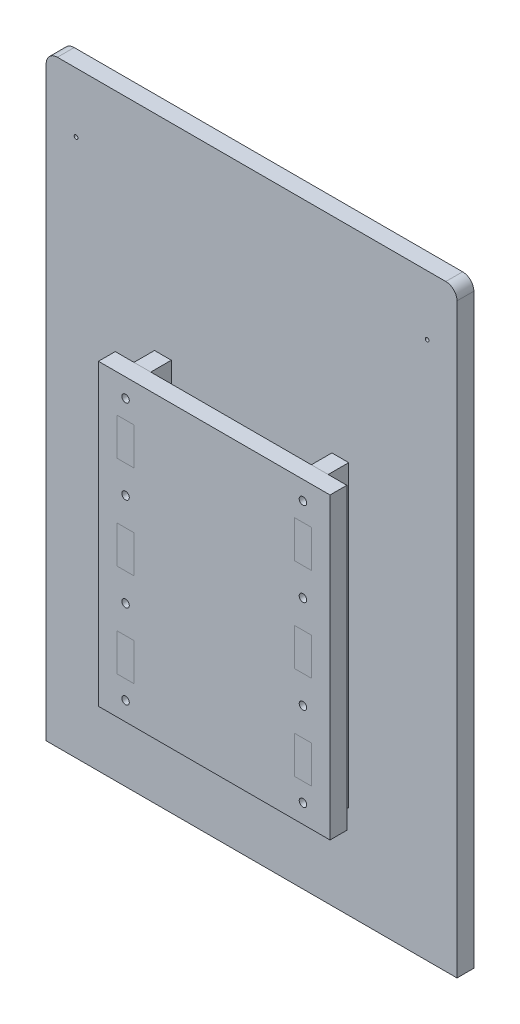
from build123d import *

# Parameters (mm, degrees)
MODEL_R            = 1
MODEL_W            = 124
MODEL_H            = 160
MODEL_R_2          = 2
MODEL_W_2          = 9
MODEL_H_2          = 20
MODEL_H_3          = 30
BOSS_EXTRU_1_DEPTH = 9
BOSS_EXTRU_3_START = 9
MODEL_3_W          = 9
MODEL_3_H          = 20
MODEL_3_R          = 2
MODEL_3_H_2        = 30
BOSS_EXTRU_3_DEPTH = 11
MODEL_4_W          = 9
MODEL_4_H          = 20
BOSS_EXTRU_4_DEPTH = 9
MODEL_5_W          = 9
MODEL_5_H          = 20
BOSS_EXTRU_5_DEPTH = 9
BOSS_EXTRU_6_START = 20
MODEL_7_W          = 9
MODEL_7_H          = 20
MODEL_7_R          = 2
MODEL_7_H_2        = 30
BOSS_EXTRU_6_DEPTH = 9
BOSS_EXTRU_7_START = 20
MODEL_8_W          = 9
MODEL_8_H          = 20
BOSS_EXTRU_7_DEPTH = 9
BOSS_EXTRU_8_START = 20
MODEL_9_W          = 9
MODEL_9_H          = 20
BOSS_EXTRU_8_DEPTH = 9


with BuildPart() as part:
    # Model → Boss.-Extru.1 (new body)
    with BuildSketch(Plane.XY):
        with BuildLine():
            Line((110, 0), (110, 314))
            ThreePointArc((110, 314), (108.242640687, 318.242640687), (104, 320))
            Line((104, 320), (0, 320))
            Line((0, 320), (-104, 320))
            ThreePointArc((-104, 320), (-108.242640687, 318.242640687), (-110, 314))
            Line((-110, 314), (-110, 0))
            Line((-110, 0), (0, 0))
            Line((0, 0), (110, 0))
        make_face()
        with Locations((94, 288)):
            Circle(MODEL_R, mode=Mode.SUBTRACT)
        with Locations((-94, 288)):
            Circle(MODEL_R, mode=Mode.SUBTRACT)
        with Locations((0, 130)):
            Rectangle(MODEL_W, MODEL_H, mode=Mode.SUBTRACT)
        with Locations((0, 130)):
            Rectangle(MODEL_W, MODEL_H)
        with Locations((47.5, 155)):
            Circle(MODEL_R_2, mode=Mode.SUBTRACT)
        with Locations((47.5, 60)):
            Circle(MODEL_R_2, mode=Mode.SUBTRACT)
        with Locations((-47.5, 60)):
            Circle(MODEL_R_2, mode=Mode.SUBTRACT)
        with Locations((-47.5, 105)):
            Circle(MODEL_R_2, mode=Mode.SUBTRACT)
        with Locations((-47.5, 155)):
            Circle(MODEL_R_2, mode=Mode.SUBTRACT)
        with Locations((-47.5, 200)):
            Circle(MODEL_R_2, mode=Mode.SUBTRACT)
        with Locations((47.5, 105)):
            Circle(MODEL_R_2, mode=Mode.SUBTRACT)
        with Locations((47.5, 200)):
            Circle(MODEL_R_2, mode=Mode.SUBTRACT)
        with Locations((-47.5, 130)):
            Rectangle(MODEL_W_2, MODEL_H_2, mode=Mode.SUBTRACT)
        with Locations((-47.5, 80)):
            Rectangle(MODEL_W_2, MODEL_H_2, mode=Mode.SUBTRACT)
        with Locations((-47.5, 180)):
            Rectangle(MODEL_W_2, MODEL_H_2, mode=Mode.SUBTRACT)
        with Locations((47.5, 130)):
            Rectangle(MODEL_W_2, MODEL_H_2, mode=Mode.SUBTRACT)
        with Locations((47.5, 80)):
            Rectangle(MODEL_W_2, MODEL_H_2, mode=Mode.SUBTRACT)
        with Locations((47.5, 180)):
            Rectangle(MODEL_W_2, MODEL_H_2, mode=Mode.SUBTRACT)
        Polygon((-52, 170), (-52, 190), (-52, 210), (-62, 210), (-62, 50), (-52, 50), (-52, 70), (-52, 90), (-52, 120), (-52, 140), align=None)
        with Locations((-47.5, 200)):
            Rectangle(MODEL_W_2, MODEL_H_2)
        with Locations((-47.5, 200)):
            Circle(MODEL_R_2, mode=Mode.SUBTRACT)
        with Locations((-47.5, 155)):
            Rectangle(MODEL_W_2, MODEL_H_3)
        with Locations((-47.5, 155)):
            Circle(MODEL_R_2, mode=Mode.SUBTRACT)
        with Locations((-47.5, 105)):
            Rectangle(MODEL_W_2, MODEL_H_3)
        with Locations((-47.5, 105)):
            Circle(MODEL_R_2, mode=Mode.SUBTRACT)
        with Locations((-47.5, 60)):
            Rectangle(MODEL_W_2, MODEL_H_2)
        with Locations((-47.5, 60)):
            Circle(MODEL_R_2, mode=Mode.SUBTRACT)
        Polygon((62, 210), (52, 210), (52, 190), (52, 170), (52, 140), (52, 120), (52, 90), (52, 70), (52, 50), (62, 50), align=None)
        with Locations((47.5, 60)):
            Rectangle(MODEL_W_2, MODEL_H_2)
        with Locations((47.5, 60)):
            Circle(MODEL_R_2, mode=Mode.SUBTRACT)
        with Locations((47.5, 105)):
            Rectangle(MODEL_W_2, MODEL_H_3)
        with Locations((47.5, 105)):
            Circle(MODEL_R_2, mode=Mode.SUBTRACT)
        with Locations((47.5, 155)):
            Rectangle(MODEL_W_2, MODEL_H_3)
        with Locations((47.5, 155)):
            Circle(MODEL_R_2, mode=Mode.SUBTRACT)
        with Locations((47.5, 200)):
            Rectangle(MODEL_W_2, MODEL_H_2)
        with Locations((47.5, 200)):
            Circle(MODEL_R_2, mode=Mode.SUBTRACT)
    extrude(amount=BOSS_EXTRU_1_DEPTH)


with BuildPart() as body_2:
    # Model_3 → Boss.-Extru.3 (new body)
    with BuildSketch(Plane.XY.offset(BOSS_EXTRU_3_START)):
        with Locations((-47.5, 200)):
            Rectangle(MODEL_3_W, MODEL_3_H)
        with Locations((-47.5, 200)):
            Circle(MODEL_3_R, mode=Mode.SUBTRACT)
        with Locations((-47.5, 155)):
            Rectangle(MODEL_3_W, MODEL_3_H_2)
        with Locations((-47.5, 155)):
            Circle(MODEL_3_R, mode=Mode.SUBTRACT)
        with Locations((-47.5, 105)):
            Rectangle(MODEL_3_W, MODEL_3_H_2)
        with Locations((-47.5, 105)):
            Circle(MODEL_3_R, mode=Mode.SUBTRACT)
        with Locations((-47.5, 60)):
            Rectangle(MODEL_3_W, MODEL_3_H)
        with Locations((-47.5, 60)):
            Circle(MODEL_3_R, mode=Mode.SUBTRACT)
        with Locations((-47.5, 80)):
            Rectangle(MODEL_3_W, MODEL_3_H)
        with Locations((-47.5, 130)):
            Rectangle(MODEL_3_W, MODEL_3_H)
        with Locations((-47.5, 180)):
            Rectangle(MODEL_3_W, MODEL_3_H)
        with Locations((47.5, 200)):
            Rectangle(MODEL_3_W, MODEL_3_H)
        with Locations((47.5, 200)):
            Circle(MODEL_3_R, mode=Mode.SUBTRACT)
        with Locations((47.5, 180)):
            Rectangle(MODEL_3_W, MODEL_3_H)
        with Locations((47.5, 155)):
            Rectangle(MODEL_3_W, MODEL_3_H_2)
        with Locations((47.5, 155)):
            Circle(MODEL_3_R, mode=Mode.SUBTRACT)
        with Locations((47.5, 130)):
            Rectangle(MODEL_3_W, MODEL_3_H)
        with Locations((47.5, 105)):
            Rectangle(MODEL_3_W, MODEL_3_H_2)
        with Locations((47.5, 105)):
            Circle(MODEL_3_R, mode=Mode.SUBTRACT)
        with Locations((47.5, 80)):
            Rectangle(MODEL_3_W, MODEL_3_H)
        with Locations((47.5, 60)):
            Rectangle(MODEL_3_W, MODEL_3_H)
        with Locations((47.5, 60)):
            Circle(MODEL_3_R, mode=Mode.SUBTRACT)
    extrude(amount=BOSS_EXTRU_3_DEPTH)

    # Model_4 → Boss.-Extru.4 (add)
    with BuildSketch(Plane.XY):
        with Locations((-47.5, 180)):
            Rectangle(MODEL_4_W, MODEL_4_H)
        with Locations((-47.5, 130)):
            Rectangle(MODEL_4_W, MODEL_4_H)
        with Locations((-47.5, 80)):
            Rectangle(MODEL_4_W, MODEL_4_H)
    extrude(amount=BOSS_EXTRU_4_DEPTH)

    # Model_5 → Boss.-Extru.5 (add)
    with BuildSketch(Plane.XY):
        with Locations((47.5, 180)):
            Rectangle(MODEL_5_W, MODEL_5_H)
        with Locations((47.5, 130)):
            Rectangle(MODEL_5_W, MODEL_5_H)
        with Locations((47.5, 80)):
            Rectangle(MODEL_5_W, MODEL_5_H)
    extrude(amount=BOSS_EXTRU_5_DEPTH)

    # Model_8 → Boss.-Extru.7 (add)
    with BuildSketch(Plane.XY.offset(BOSS_EXTRU_7_START)):
        with Locations((-47.5, 130)):
            Rectangle(MODEL_8_W, MODEL_8_H)
        with Locations((-47.5, 80)):
            Rectangle(MODEL_8_W, MODEL_8_H)
        with Locations((-47.5, 180)):
            Rectangle(MODEL_8_W, MODEL_8_H)
    extrude(amount=BOSS_EXTRU_7_DEPTH)

    # Model_9 → Boss.-Extru.8 (add)
    with BuildSketch(Plane.XY.offset(BOSS_EXTRU_8_START)):
        with Locations((47.5, 180)):
            Rectangle(MODEL_9_W, MODEL_9_H)
        with Locations((47.5, 80)):
            Rectangle(MODEL_9_W, MODEL_9_H)
        with Locations((47.5, 130)):
            Rectangle(MODEL_9_W, MODEL_9_H)
    extrude(amount=BOSS_EXTRU_8_DEPTH)


with BuildPart() as body_3:
    # Model_7 → Boss.-Extru.6 (new body)
    with BuildSketch(Plane.XY.offset(BOSS_EXTRU_6_START)):
        Polygon((-52, 170), (-52, 190), (-52, 210), (-62, 210), (-62, 50), (-52, 50), (-52, 70), (-52, 90), (-52, 120), (-52, 140), align=None)
        with Locations((-47.5, 200)):
            Rectangle(MODEL_7_W, MODEL_7_H)
        with Locations((-47.5, 200)):
            Circle(MODEL_7_R, mode=Mode.SUBTRACT)
        with Locations((-47.5, 155)):
            Rectangle(MODEL_7_W, MODEL_7_H_2)
        with Locations((-47.5, 155)):
            Circle(MODEL_7_R, mode=Mode.SUBTRACT)
        with Locations((-47.5, 105)):
            Rectangle(MODEL_7_W, MODEL_7_H_2)
        with Locations((-47.5, 105)):
            Circle(MODEL_7_R, mode=Mode.SUBTRACT)
        with Locations((-47.5, 60)):
            Rectangle(MODEL_7_W, MODEL_7_H)
        with Locations((-47.5, 60)):
            Circle(MODEL_7_R, mode=Mode.SUBTRACT)
        Polygon((-43, 210), (-43, 190), (-43, 170), (-43, 140), (-43, 120), (-43, 90), (-43, 70), (-43, 50), (43, 50), (43, 70), (43, 90), (43, 120), (43, 140), (43, 170), (43, 190), (43, 210), align=None)
        with Locations((47.5, 200)):
            Rectangle(MODEL_7_W, MODEL_7_H)
        with Locations((47.5, 200)):
            Circle(MODEL_7_R, mode=Mode.SUBTRACT)
        Polygon((62, 210), (52, 210), (52, 190), (52, 170), (52, 140), (52, 120), (52, 90), (52, 70), (52, 50), (62, 50), align=None)
        with Locations((47.5, 155)):
            Rectangle(MODEL_7_W, MODEL_7_H_2)
        with Locations((47.5, 155)):
            Circle(MODEL_7_R, mode=Mode.SUBTRACT)
        with Locations((47.5, 105)):
            Rectangle(MODEL_7_W, MODEL_7_H_2)
        with Locations((47.5, 105)):
            Circle(MODEL_7_R, mode=Mode.SUBTRACT)
        with Locations((47.5, 60)):
            Rectangle(MODEL_7_W, MODEL_7_H)
        with Locations((47.5, 60)):
            Circle(MODEL_7_R, mode=Mode.SUBTRACT)
    extrude(amount=BOSS_EXTRU_6_DEPTH)


solid = Compound([part.part, body_2.part, body_3.part])
